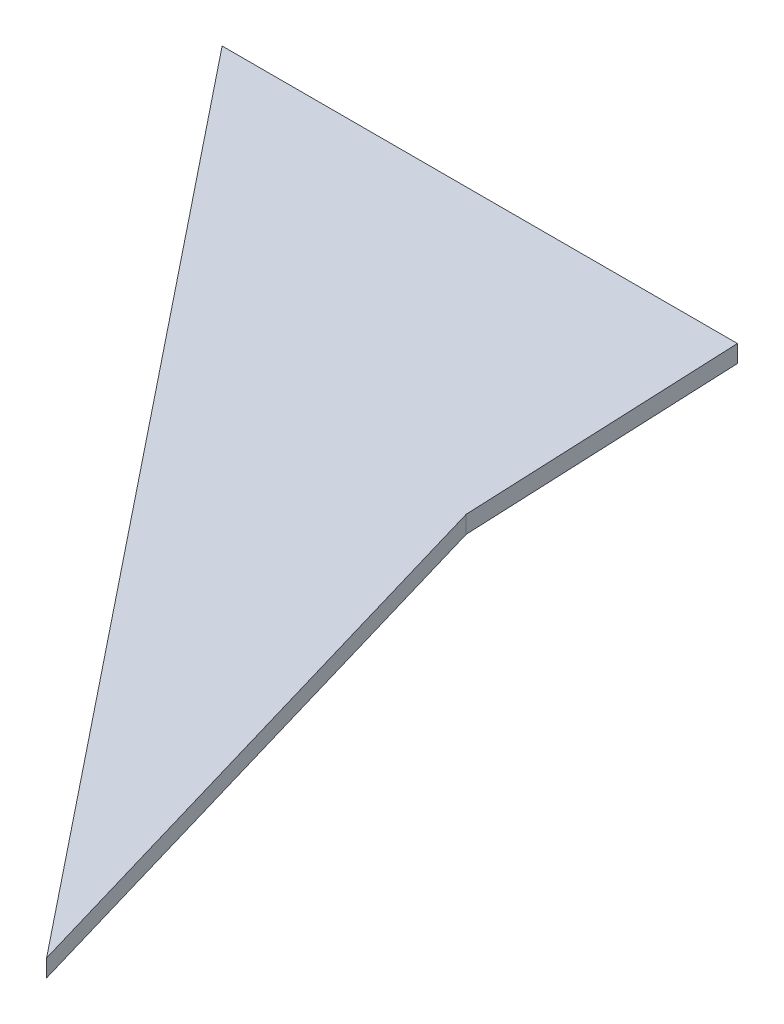
from build123d import *

# Parameters (mm, degrees)
BOSS_EXTRU_1_DEPTH = 2


with BuildPart() as part:
    # Esquisse1 → Boss.-Extru.1 (new body)
    with BuildSketch(Plane(origin=(0, 0, 0), x_dir=(1, 0, 0), z_dir=(0, 1, 0))):
        Polygon((0, 0), (80.834545874, -101.050384073), (60.747774825, -32.642465135), (59.334250083, 0), align=None)
    extrude(amount=BOSS_EXTRU_1_DEPTH)


solid = part.part
